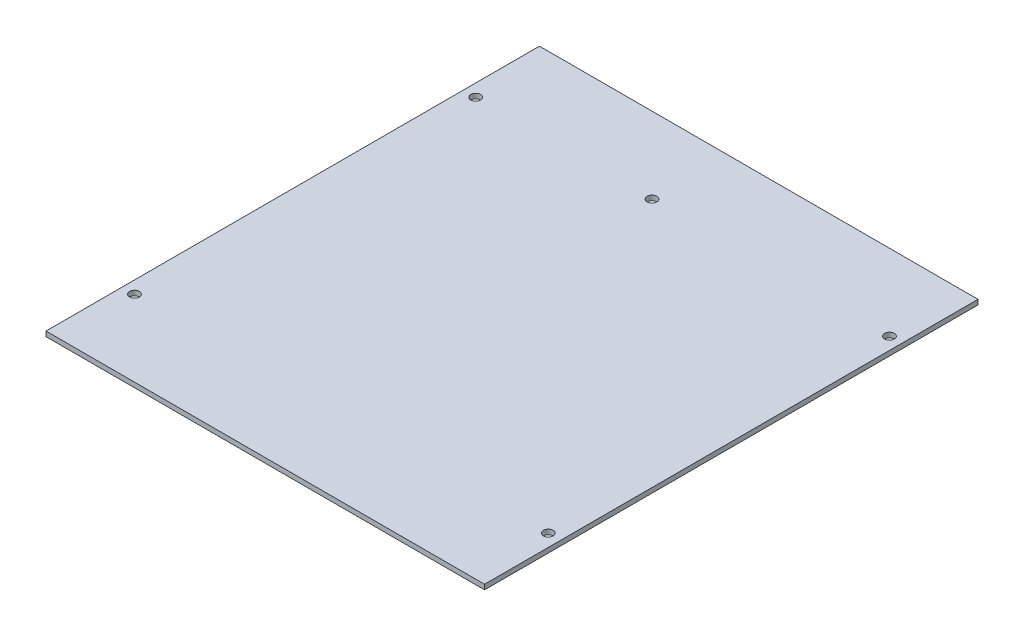
from build123d import *

# Parameters (mm, degrees)
SKETCH_2_W      = 144.018
SKETCH_2_H      = 162.052
EXTRUDE_1_DEPTH = 1.6
F_5_0MM_1_D     = 3.2


with BuildPart() as part:
    # 草圖2 → 填料-伸長1 (new body)
    with BuildSketch(Plane(origin=(0, 0, 0), x_dir=(1, 0, 0), z_dir=(0, 1, 0))):
        with Locations((-72.009, 81.026)):
            Rectangle(SKETCH_2_W, SKETCH_2_H)
    extrude(amount=EXTRUDE_1_DEPTH)

    # Ø5.0mm 定位孔1 (through all)
    with Locations(Plane(origin=(0, 1.6, 0), x_dir=(1, 0, 0), z_dir=(0, 1, 0))):
        with Locations((-139.954, 137.033), (-82.042, 137.033), (-4.064, 137.033), (-4.064, 25.019), (-139.954, 25.019)):
            Hole(F_5_0MM_1_D / 2)


solid = part.part
